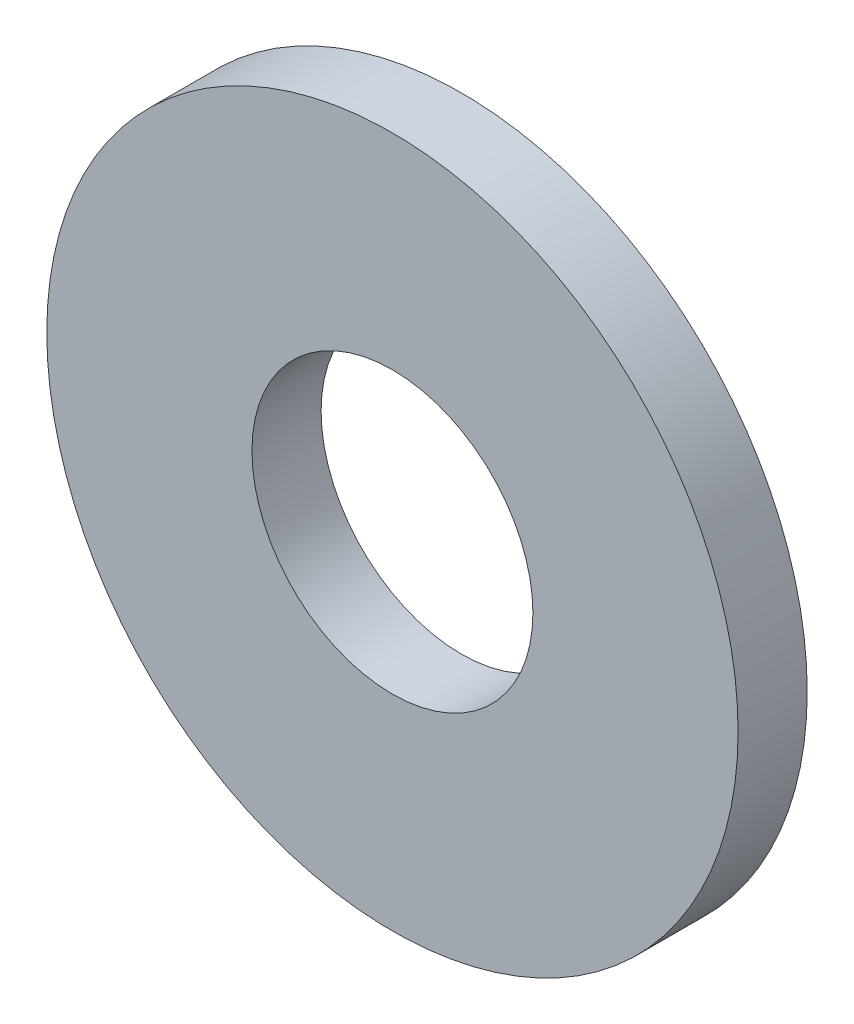
from build123d import *

# Parameters (mm, degrees)
SKETCH1_R      = 7.9375
SKETCH1_R_2    = 3.2258
EXTRUDE1_DEPTH = 0.79375


with BuildPart() as part:
    # Sketch1 → Extrude1 (new body, symmetric)
    with BuildSketch(Plane.XY):
        Circle(SKETCH1_R)
        Circle(SKETCH1_R_2, mode=Mode.SUBTRACT)
    extrude(amount=EXTRUDE1_DEPTH, both=True)


solid = part.part
